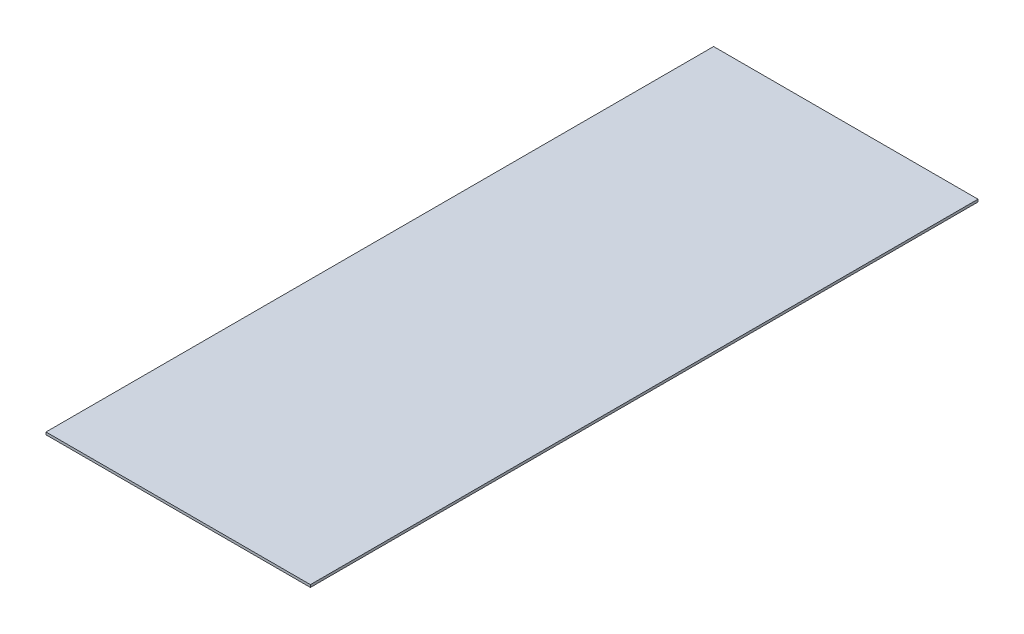
from build123d import *

# Parameters (mm, degrees)
SKETCH1_W           = 160
SKETCH1_H           = 404
BOSS_EXTRUDE1_DEPTH = 1.5


with BuildPart() as part:
    # Sketch1 → Boss-Extrude1 (new body)
    with BuildSketch(Plane(origin=(0, 0, 0.047945548), x_dir=(1, 0, 0), z_dir=(0, 1, 0))):
        with Locations((47.787450107, -2.079150986)):
            Rectangle(SKETCH1_W, SKETCH1_H)
    extrude(amount=BOSS_EXTRUDE1_DEPTH)


solid = part.part
